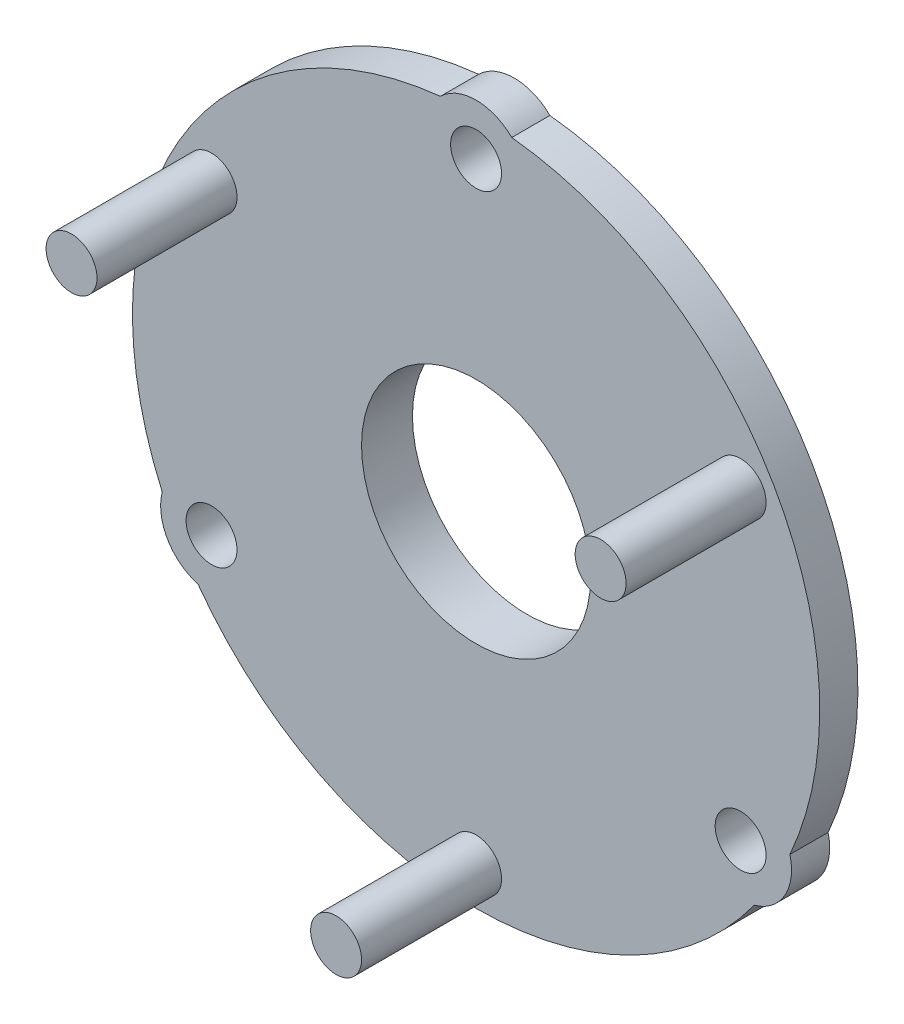
from build123d import *

# Parameters (mm, degrees)
BASE_EXTRUSION_DEPTH    = 1.5
ESQUISSE2_R             = 1
ENL_V_MAT_EXTRU_1_DEPTH = 2.5
ESQUISSE3_R             = 1
BOSS_EXTRU_1_DEPTH      = 5.5
ESQUISSE4_R             = 6
BOSS_EXTRU_2_DEPTH      = 0.5
ESQUISSE5_R             = 4.5
ENL_V_MAT_EXTRU_2_DEPTH = 8.5


with BuildPart() as part:
    # Esquisse1 → Base-Extrusion (new body)
    with BuildSketch(Plane.XY):
        with BuildLine():
            ThreePointArc((12.328808061, -5.500044708), (11.691342951, 6.75), (1.401225592, 13.427083333))
            ThreePointArc((1.401225592, 13.427083333), (0, 14), (-1.401225592, 13.427083333))
            ThreePointArc((-1.401225592, 13.427083333), (-11.691342951, 6.75), (-12.328808061, -5.500044708))
            ThreePointArc((-12.328808061, -5.500044708), (-12.124355653, -7), (-10.927582469, -7.927038626))
            ThreePointArc((-10.927582469, -7.927038626), (0, -13.5), (10.927582469, -7.927038626))
            ThreePointArc((10.927582469, -7.927038626), (12.124355653, -7), (12.328808061, -5.500044708))
        make_face()
    extrude(amount=BASE_EXTRUSION_DEPTH)

    # Esquisse2 → Enlèv. mat.-Extru.1 (cut, through all)
    with BuildSketch(Plane.XY.offset(1.5)):
        with Locations((0, 12)):
            Circle(ESQUISSE2_R)
        with Locations((10.392304845, -6)):
            Circle(ESQUISSE2_R)
        with Locations((-10.392304845, -6)):
            Circle(ESQUISSE2_R)
    extrude(amount=-ENL_V_MAT_EXTRU_1_DEPTH, mode=Mode.SUBTRACT)

    # Esquisse3 → Boss.-Extru.1 (add)
    with BuildSketch(Plane.XY.offset(1.5)):
        with Locations((10.392304845, 6)):
            Circle(ESQUISSE3_R)
        with Locations((0, -12)):
            Circle(ESQUISSE3_R)
        with Locations((-10.392304845, 6)):
            Circle(ESQUISSE3_R)
    extrude(amount=BOSS_EXTRU_1_DEPTH)

    # Esquisse4 → Boss.-Extru.2 (add)
    with BuildSketch(Plane(origin=(0, 0, 0), x_dir=(-1, 0, 0), z_dir=(0, 0, -1))):
        Circle(ESQUISSE4_R)
    extrude(amount=BOSS_EXTRU_2_DEPTH)

    # Esquisse5 → Enlèv. mat.-Extru.2 (cut, through all)
    with BuildSketch(Plane(origin=(0, 0, -0.5), x_dir=(-1, 0, 0), z_dir=(0, 0, -1))):
        Circle(ESQUISSE5_R)
    extrude(amount=-ENL_V_MAT_EXTRU_2_DEPTH, mode=Mode.SUBTRACT)


solid = part.part
